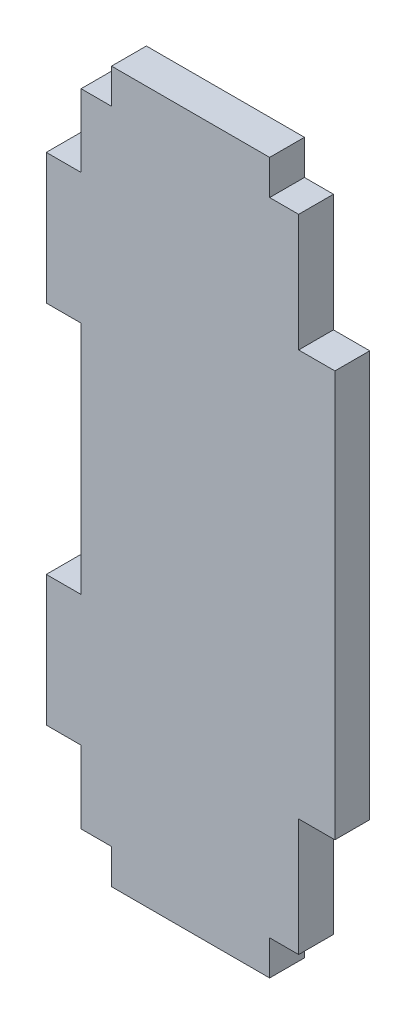
from build123d import *

# Parameters (mm, degrees)
BOSS_EXTRUDE1_DEPTH = 3.048


with BuildPart() as part:
    # Sketch1 → Boss-Extrude1 (new body)
    with BuildSketch(Plane.XY):
        Polygon((-22.225, -3.048), (-19.558, -3.048), (-19.558, 0), (-5.715, 0), (-5.715, -3.048), (-3.175, -3.048), (-3.175, -13.335), (0, -13.335), (0, -48.895), (-3.175, -48.895), (-3.175, -59.182), (-5.715, -59.182), (-5.715, -62.23), (-19.558, -62.23), (-19.558, -59.182), (-22.225, -59.182), (-22.225, -52.832), (-25.273, -52.832), (-25.273, -41.402), (-22.225, -41.402), (-22.225, -20.828), (-25.273, -20.828), (-25.273, -9.398), (-22.225, -9.398), align=None)
    extrude(amount=BOSS_EXTRUDE1_DEPTH)


solid = part.part
